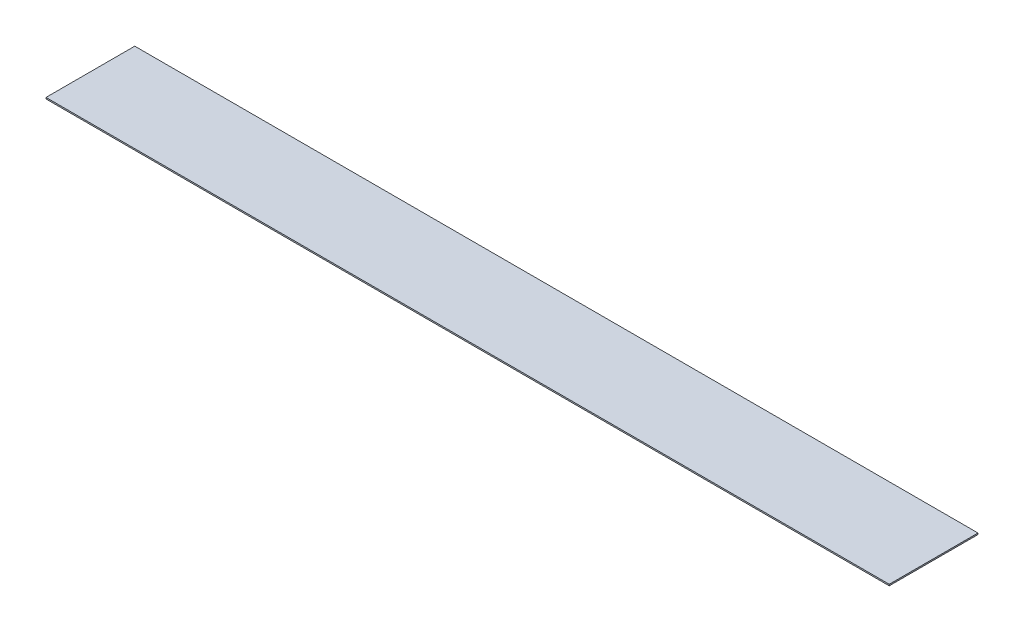
from build123d import *

# Parameters (mm, degrees)
SKETCH1_W           = 965.2
SKETCH1_H           = 101.6
BOSS_EXTRUDE1_DEPTH = 1.5875


with BuildPart() as part:
    # Sketch1 → Boss-Extrude1 (new body)
    with BuildSketch(Plane(origin=(0, 0, 0), x_dir=(1, 0, 0), z_dir=(0, 1, 0))):
        with Locations((482.6, 50.8)):
            Rectangle(SKETCH1_W, SKETCH1_H)
    extrude(amount=BOSS_EXTRUDE1_DEPTH)


solid = part.part
